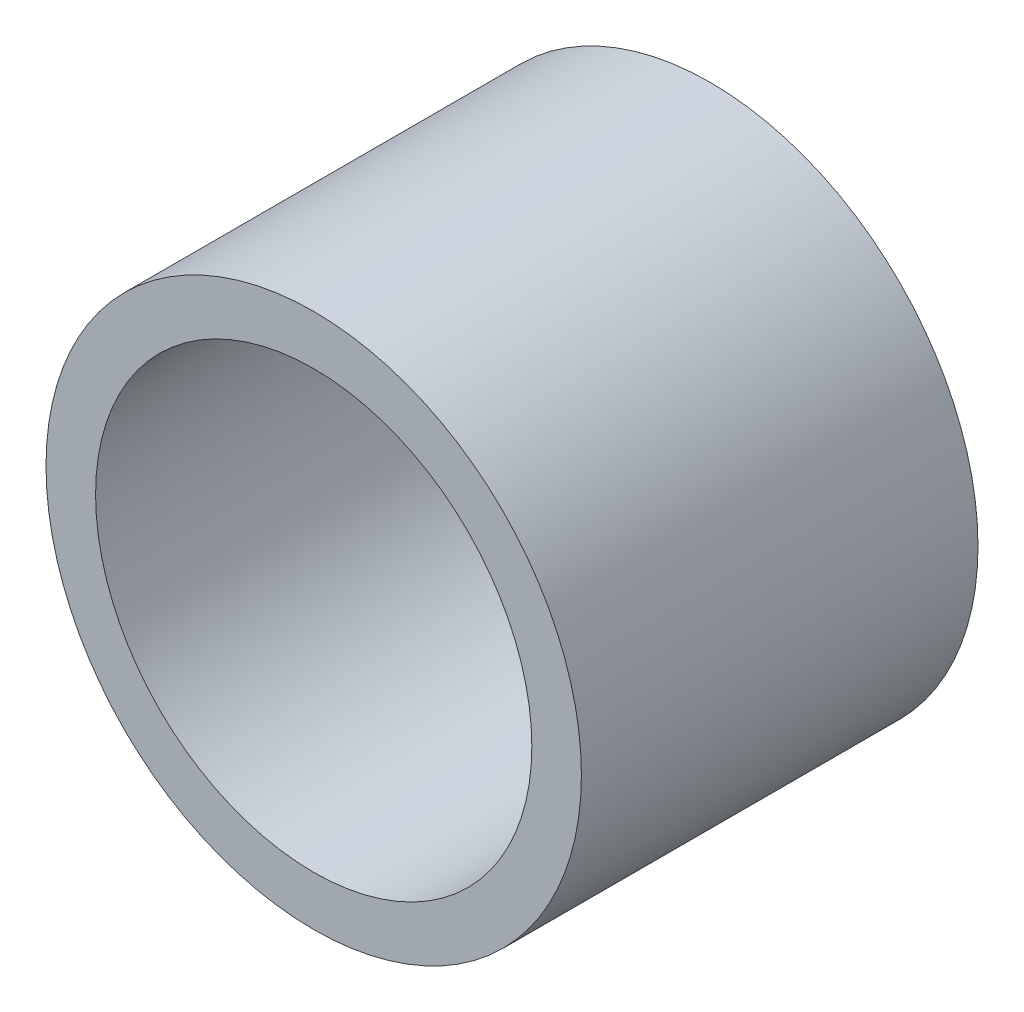
from build123d import *

# Parameters (mm, degrees)
SKETCH_1_R      = 13.5
SKETCH_1_R_2    = 11
EXTRUDE_1_DEPTH = 20


with BuildPart() as part:
    # 草圖1 → 填料-伸長1 (new body)
    with BuildSketch(Plane.XY):
        Circle(SKETCH_1_R)
        Circle(SKETCH_1_R_2, mode=Mode.SUBTRACT)
    extrude(amount=EXTRUDE_1_DEPTH)


solid = part.part
